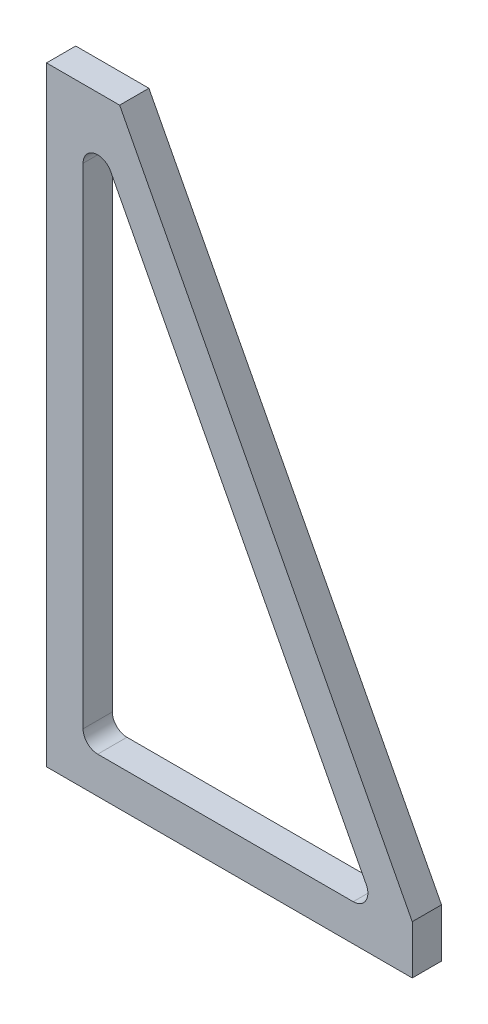
from build123d import *

# Parameters (mm, degrees)
BOSS_EXTRUDE2_DEPTH = 12


with BuildPart() as part:
    # Sketch1 → Boss-Extrude2 (new body)
    with BuildSketch(Plane.XY):
        Polygon((0, 0), (150, 0), (150, 20), (30, 250), (0, 250), align=None)
        with BuildLine():
            Line((15, 221.851073801), (15, 21))
            ThreePointArc((15, 21), (16.757359313, 16.757359313), (21, 15))
            Line((21, 15), (125.791864592, 15))
            ThreePointArc((125.791864592, 15), (130.922769787, 17.88972479), (131.111373669, 23.77539604))
            Line((131.111373669, 23.77539604), (26.319509077, 224.626469841))
            ThreePointArc((26.319509077, 224.626469841), (19.571198835, 227.67846835), (15, 221.851073801))
        make_face(mode=Mode.SUBTRACT)
    extrude(amount=BOSS_EXTRUDE2_DEPTH)


solid = part.part
